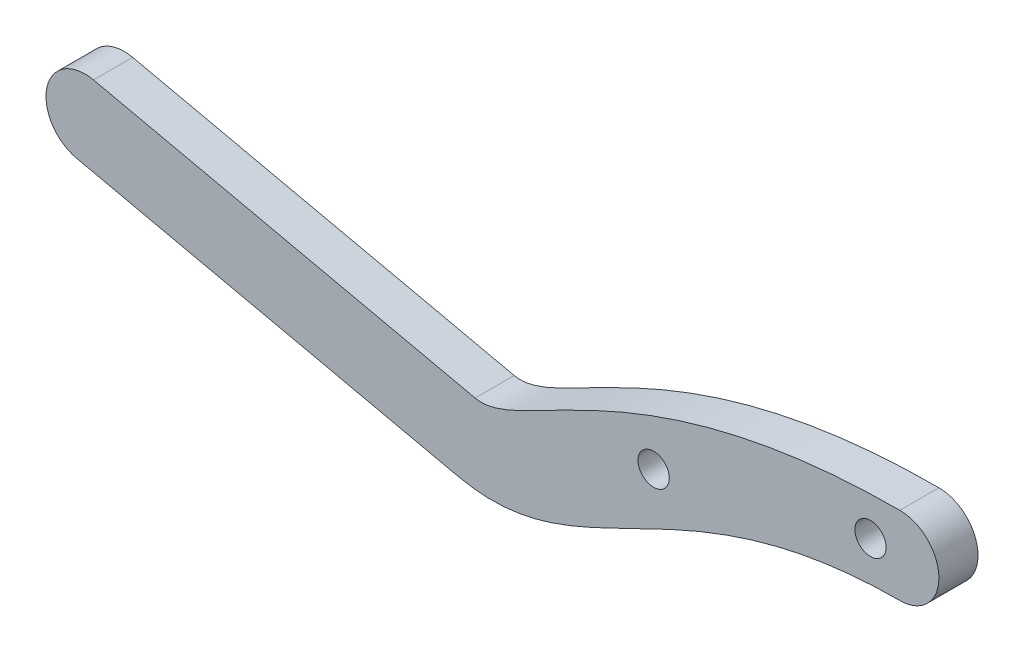
from build123d import *

# Parameters (mm, degrees)
SKETCH1_R           = 1.6
BOSS_EXTRUDE1_DEPTH = 4


with BuildPart() as part:
    # Sketch1 → Boss-Extrude1 (new body)
    with BuildSketch(Plane.XY):
        with BuildLine():
            Line((-81.241225793, -6.924028443), (-42.192224122, -15.594407241))
            add(Edge.make_bspline(
                [(-42.192224122, -15.594407241), (-29.042309964, -18.51419346), (-20.671199627, -4), (3, -4)],
                knots=[0, 0, 0, 0, 1, 1, 1, 1], degree=3))
            ThreePointArc((3, -4), (7, 0), (3, 4))
            add(Edge.make_bspline(
                [(-40.458148362, -7.784606907), (-35.521822822, -8.880660851), (-24.58512885, 4), (3, 4)],
                knots=[0, 0, 0, 0, 1, 1, 1, 1], degree=3))
            Line((-40.458148362, -7.784606907), (-79.507150033, 0.885771891))
            ThreePointArc((-79.507150033, 0.885771891), (-84.27908808, -2.152090396), (-81.241225793, -6.924028443))
        make_face()
        with Locations((-22.192224122, -4.956209462)):
            Circle(SKETCH1_R, mode=Mode.SUBTRACT)
        Circle(SKETCH1_R, mode=Mode.SUBTRACT)
    extrude(amount=BOSS_EXTRUDE1_DEPTH)


solid = part.part
